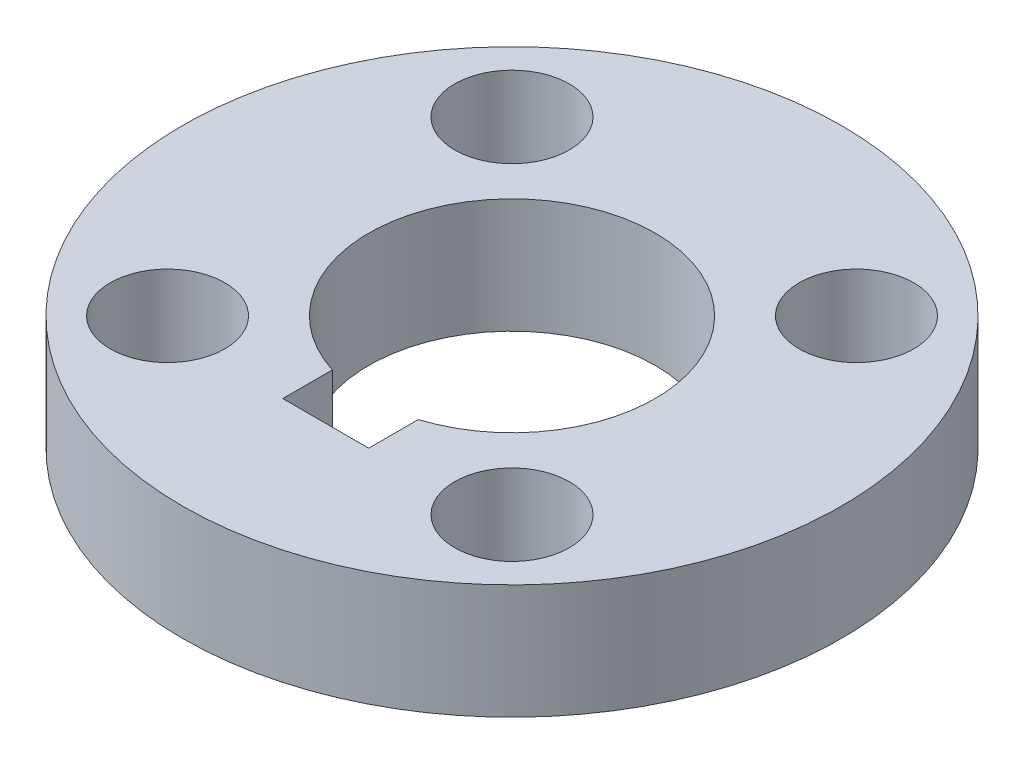
from build123d import *

# Parameters (mm, degrees)
ESQUISSE1_R                  = 23
ESQUISSE1_R_2                = 10
BOSS_EXTRU_1_DEPTH           = 8
ENL_V_MAT_EXTRU_1_DEPTH      = 3
ENL_V_MAT_EXTRU_1_DEPTH_BACK = 1
ESQUISSE4_R                  = 4
ENL_V_MAT_EXTRU_2_DEPTH      = 9
R_P_TITION_CIRCULAIRE1_COUNT = 4


with BuildPart() as part:
    # Esquisse1 → Boss.-Extru.1 (new body)
    with BuildSketch(Plane(origin=(0, 0, 0), x_dir=(1, 0, 0), z_dir=(0, 1, 0))):
        with Locations(Location((0, 0, 0), (0, 0, 270))):  # turned: the seam where the file's is
            Circle(ESQUISSE1_R)
        with Locations(Location((0, 0, 0), (0, 0, 270))):  # turned: the seam where the file's is
            Circle(ESQUISSE1_R_2, mode=Mode.SUBTRACT)
    extrude(amount=BOSS_EXTRU_1_DEPTH)

    # Esquisse2 → Enlèv. mat.-Extru.1 (cut, two sides)
    with BuildSketch(Plane.XY.offset(10)) as enl_v_mat_extru_1_sk:
        with BuildLine():
            Line((-3, 0), (-3, 12))
            ThreePointArc((-3, 12), (0, 15), (3, 12))
            Line((3, 12), (3, 0))
            ThreePointArc((3, 0), (0, -3), (-3, 0))
        make_face()
    extrude(amount=ENL_V_MAT_EXTRU_1_DEPTH, mode=Mode.SUBTRACT)
    extrude(enl_v_mat_extru_1_sk.sketch, amount=-ENL_V_MAT_EXTRU_1_DEPTH_BACK, mode=Mode.SUBTRACT)

    # Esquisse4 → Enlèv. mat.-Extru.2 (cut, through all)
    with BuildSketch(Plane.XZ):
        with Locations(Location((12.02081528, 12.02081528, 0), (0, 0, 270))):  # turned: the seam where the file's is
            Circle(ESQUISSE4_R)
    enl_v_mat_extru_2 = extrude(amount=-ENL_V_MAT_EXTRU_2_DEPTH, mode=Mode.SUBTRACT)

    # Répétition circulaire1: Enlèv. mat.-Extru.2 ×4 about axis
    r_p_tition_circulaire1_axis = Axis((0, 0, 0), (0, 1, 0))
    for i in range(1, R_P_TITION_CIRCULAIRE1_COUNT):
        add(enl_v_mat_extru_2.rotate(r_p_tition_circulaire1_axis, i * 360 / R_P_TITION_CIRCULAIRE1_COUNT), mode=Mode.SUBTRACT)


solid = part.part
